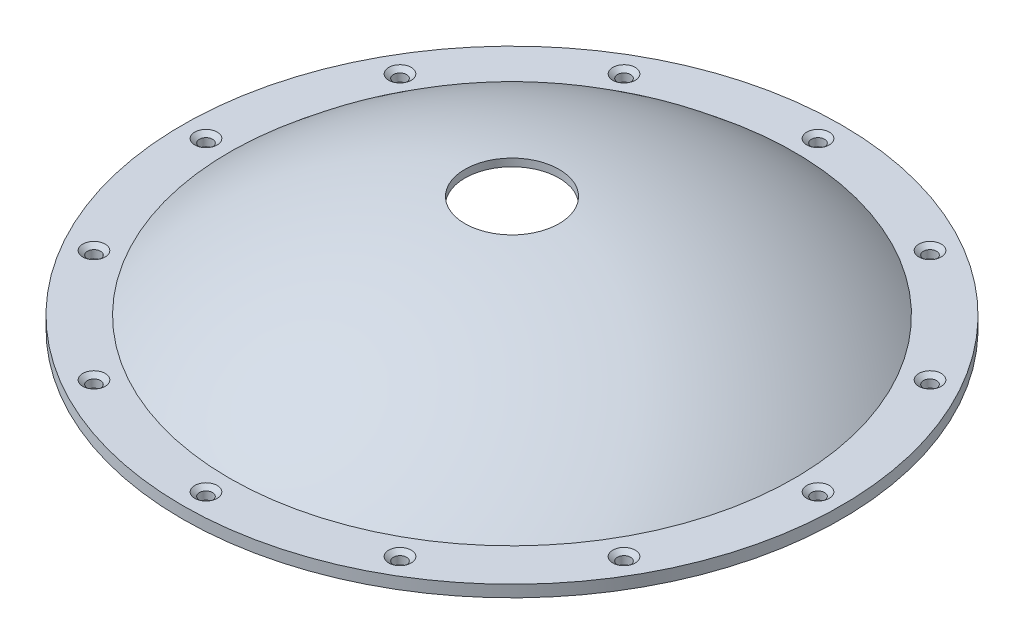
from build123d import *

# Parameters (mm, degrees)
CSK_FOR_0_FLAT_HEAD_MACHINE_SCREW_100_D           = 1.778
CSK_FOR_0_FLAT_HEAD_MACHINE_SCREW_100_CSINK_D     = 3.0226
CSK_FOR_0_FLAT_HEAD_MACHINE_SCREW_100_CSINK_ANGLE = 100
CIRPATTERN1_COUNT                                 = 12


with BuildPart() as part:
    # Sketch1 → Revolve1 (revolve)
    with BuildSketch(Plane.XY):
        with BuildLine():
            Line((-44.45, 0), (-38.1, 0))
            ThreePointArc((-38.1, 0), (-38.054138834, 0.213808772), (-37.924624138, 0.390000091))
            ThreePointArc((-37.924624138, 0.390000091), (-23.22414199, 9.855095754), (-6.35, 14.432818263))
            Line((-6.35, 14.432818263), (-6.35, 15.455036958))
            ThreePointArc((-6.35, 15.455036958), (-23.281489865, 10.940122909), (-38.1, 1.5875))
            Line((-38.1, 1.5875), (-44.45, 1.5875))
            Line((-44.45, 1.5875), (-44.45, 0))
        make_face()
    revolve(axis=Axis((0, 55, 0), (0, -1, 0)))

    # CSK for #0 Flat Head Machine Screw (100)1 (through all)
    with Locations(Plane(origin=(0, 1.5875, 0), x_dir=(1, 0, 0), z_dir=(0, 1, 0))):
        with Locations((-41.275, 0)):
            csk_for_0_flat_head_machine_screw_100 = CounterSinkHole(CSK_FOR_0_FLAT_HEAD_MACHINE_SCREW_100_D / 2, CSK_FOR_0_FLAT_HEAD_MACHINE_SCREW_100_CSINK_D / 2, counter_sink_angle=CSK_FOR_0_FLAT_HEAD_MACHINE_SCREW_100_CSINK_ANGLE)

    # CirPattern1: CSK for #0 Flat Head Machine Screw (100)1 ×12 about axis
    cirpattern1_axis = Axis((0, 0, 0), (0, 1, 0))
    for i in range(1, CIRPATTERN1_COUNT):
        add(csk_for_0_flat_head_machine_screw_100.rotate(cirpattern1_axis, i * 360 / CIRPATTERN1_COUNT), mode=Mode.SUBTRACT)


solid = part.part
